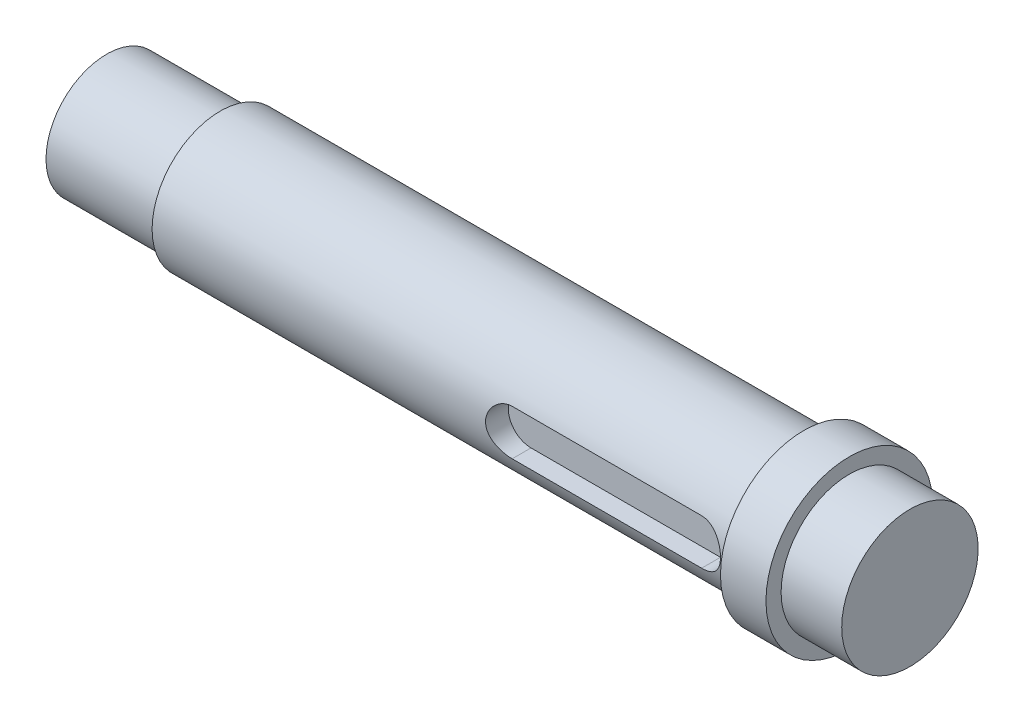
from build123d import *

# Parameters (mm, degrees)
CUT_EXTRUDE_2_DEPTH = 3


with BuildPart() as part:
    # 草图2 → 旋转1 (revolve)
    with BuildSketch(Plane(origin=(0, 0, 0), x_dir=(1, 0, 0), z_dir=(0, 1, 0))):
        Polygon((0, 0), (0, 8), (15, 8), (15, 9), (92, 9), (92, 11), (98, 11), (98, 9), (106, 9), (106, 0), align=None)
    revolve(axis=Axis((0, 0, 0), (1, 0, 0)))

    # 草图4 → 切除-拉伸2 (cut)
    with BuildSketch(Plane.XY.offset(9)):
        with BuildLine():
            Line((62, 3), (87, 3))
            ThreePointArc((87, 3), (90, 0), (87, -3))
            Line((87, -3), (62, -3))
            ThreePointArc((62, -3), (59, 0), (62, 3))
        make_face()
    extrude(amount=-CUT_EXTRUDE_2_DEPTH, mode=Mode.SUBTRACT)


solid = part.part
